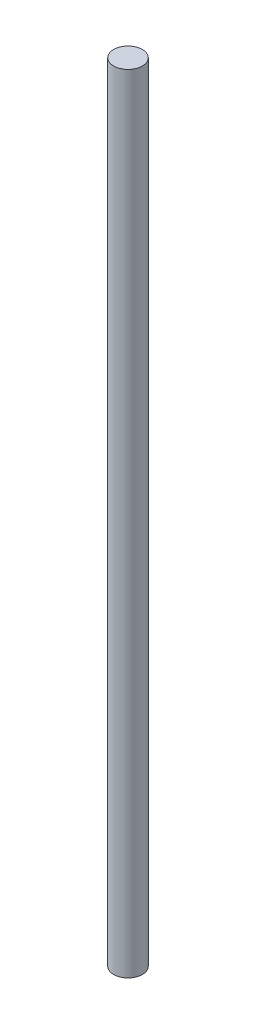
from build123d import *

# Parameters (mm, degrees)
SKETCH1_R           = 5.55625
BOSS_EXTRUDE1_DEPTH = 152.4


with BuildPart() as part:
    # Sketch1 → Boss-Extrude1 (new body, symmetric)
    with BuildSketch(Plane(origin=(0, 0, 0), x_dir=(1, 0, 0), z_dir=(0, 1, 0))):
        Circle(SKETCH1_R)
    extrude(amount=BOSS_EXTRUDE1_DEPTH, both=True)


solid = part.part
